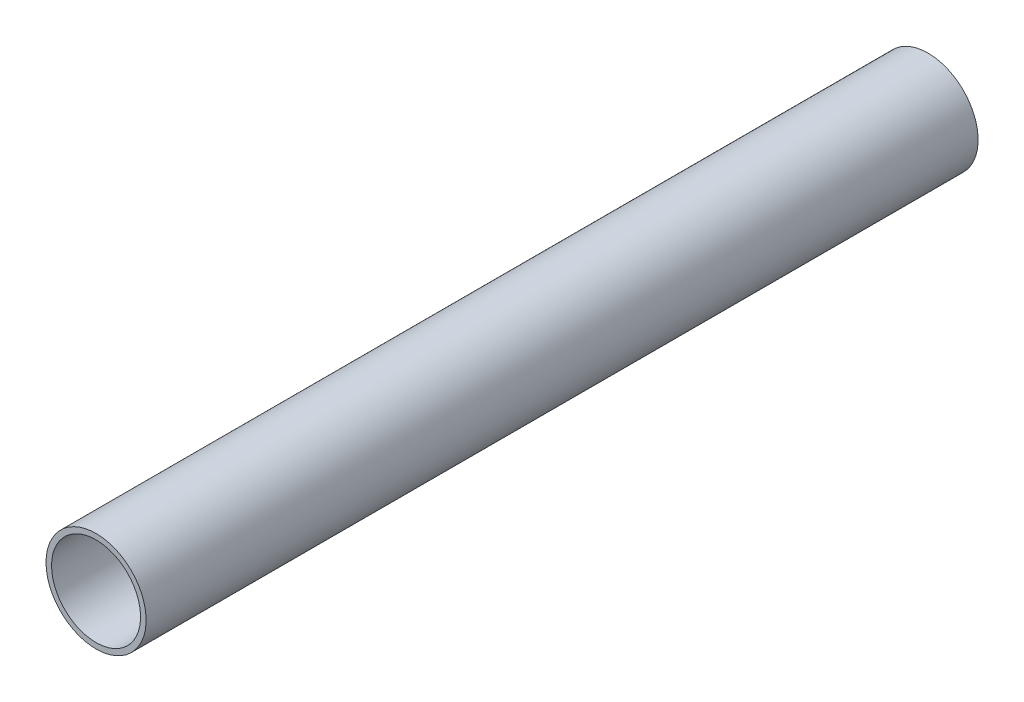
from build123d import *

# Parameters (mm, degrees)
SKETCH_1_W = 6.35
SKETCH_1_H = 950


with BuildPart() as part:
    # 草图1 → 旋转1 (revolve)
    with BuildSketch(Plane.XZ):
        with Locations((53.975, 0)):
            Rectangle(SKETCH_1_W, SKETCH_1_H)
    revolve(axis=Axis((0, 0, 475), (0, 0, -1)))


solid = part.part
